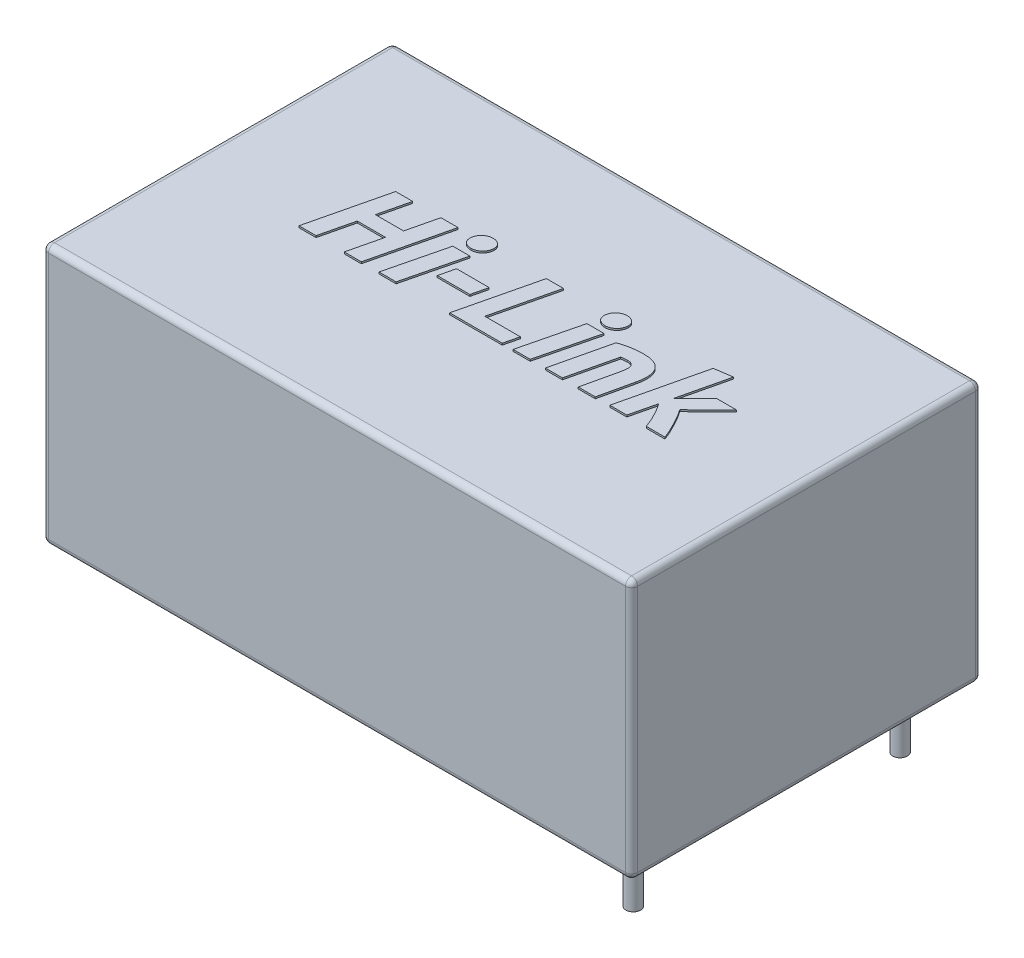
from build123d import *

# Parameters (mm, degrees)
SKETCH1_W           = 34
SKETCH1_H           = 20.2
BOSS_EXTRUDE2_DEPTH = 15
SKETCH2_R           = 0.423333333
BOSS_EXTRUDE3_DEPTH = 3.5
BOSS_EXTRUDE4_DEPTH = 0.1
FILLET1_R           = 0.35


with BuildPart() as part:
    # Sketch1 → Boss-Extrude2 (new body)
    with BuildSketch(Plane(origin=(0, 0, 0), x_dir=(1, 0, 0), z_dir=(0, 1, 0))):
        with Locations((17, 10.1)):
            Rectangle(SKETCH1_W, SKETCH1_H)
    extrude(amount=BOSS_EXTRUDE2_DEPTH)

    # Sketch2 → Boss-Extrude3 (add)
    with BuildSketch(Plane.XZ):
        with Locations((2.3, -7.6)):
            Circle(SKETCH2_R)
        with Locations((2.3, -12.6)):
            Circle(SKETCH2_R)
        with Locations((31.7, -17.8)):
            Circle(SKETCH2_R)
        with Locations((31.7, -2.4)):
            Circle(SKETCH2_R)
    extrude(amount=BOSS_EXTRUDE3_DEPTH)

    # Sketch3 → Boss-Extrude4 (add)
    with BuildSketch(Plane(origin=(0, 15, 0), x_dir=(1, 0, 0), z_dir=(0, 1, 0))):
        Polygon((10.350318867, 12.648491232), (11.335631367, 12.648491232), (10.255631367, 8.148491232), (9.270318867, 8.148491232), (9.730631367, 10.068491232), (8.102193867, 10.068491232), (7.640943867, 8.148491232), (6.655631367, 8.148491232), (7.735631367, 12.648491232), (8.720943867, 12.648491232), (8.303756367, 10.908491232), (9.932193867, 10.908491232), align=None)
        Polygon((12.261881367, 8.148491232), (11.275631367, 8.148491232), (12.115631367, 11.568491232), (13.101881367, 11.568491232), align=None)
        with BuildLine():
            add(Edge.make_bspline(
                [(12.740006367, 11.988491232), (12.706750428, 11.989888935), (12.641017262, 11.992651612), (12.54504248, 12.016096214), (12.454021343, 12.054198845), (12.3693054, 12.105674787), (12.294416137, 12.172543008), (12.243861168, 12.260416221), (12.211281809, 12.362167754), (12.208198927, 12.435396738), (12.206568867, 12.474116232)],
                knots=[0, 0, 0, 0, 9.9658e-05, 0.000196982, 0.000294482, 0.000394654, 0.000493483, 0.000591881, 0.000695065, 0.000810838, 0.000810838, 0.000810838, 0.000810838], degree=3))
            add(Edge.make_bspline(
                [(12.206568867, 12.474116232), (12.207357098, 12.496343093), (12.208930749, 12.540717558), (12.219492999, 12.606075401), (12.236249223, 12.669738795), (12.268866548, 12.750285776), (12.323943973, 12.842894269), (12.407325184, 12.940573536), (12.508626271, 13.019793742), (12.60483926, 13.068914927), (12.686220664, 13.101077481), (12.751075332, 13.115914271), (12.817405536, 13.127527259), (12.862451292, 13.128166646), (12.885318867, 13.128491232)],
                knots=[0, 0, 0, 0, 6.6668e-05, 0.000133098, 0.000198138, 0.00026377, 0.000393203, 0.000519497, 0.000647028, 0.000776186, 0.000842351, 0.000908973, 0.000975403, 0.001043899, 0.001043899, 0.001043899, 0.001043899], degree=3))
            add(Edge.make_bspline(
                [(12.885318867, 13.128491232), (12.918576393, 13.127096805), (12.984312696, 13.124340602), (13.080264362, 13.100848286), (13.171127637, 13.063030516), (13.25530803, 13.011054492), (13.329504145, 12.944303), (13.382141217, 12.857414255), (13.413780196, 12.755003721), (13.417039853, 12.681547702), (13.418756367, 12.642866232)],
                knots=[0, 0, 0, 0, 9.9658e-05, 0.000196982, 0.000294482, 0.000393857, 0.000492686, 0.00059077, 0.00069485, 0.000810623, 0.000810623, 0.000810623, 0.000810623], degree=3))
            add(Edge.make_bspline(
                [(13.418756367, 12.642866232), (13.417941865, 12.620646406), (13.416315764, 12.576285984), (13.40613027, 12.510741396), (13.387881816, 12.447390668), (13.355613399, 12.36688625), (13.301602123, 12.273466563), (13.217070196, 12.176966807), (13.116315683, 12.097232276), (13.001738312, 12.036211452), (12.874488614, 11.995753427), (12.785308356, 11.990937591), (12.740006367, 11.988491232)],
                knots=[0, 0, 0, 0, 6.6668e-05, 0.000133098, 0.000198388, 0.000264019, 0.000392979, 0.000519889, 0.000646683, 0.000776279, 0.000907653, 0.001043289, 0.001043289, 0.001043289, 0.001043289], degree=3))
        make_face()
        Polygon((13.350318867, 10.548491232), (15.235631367, 10.548491232), (15.020943867, 9.648491232), (13.135631367, 9.648491232), align=None)
        Polygon((18.595631367, 8.988491232), (18.388443867, 8.148491232), (15.355631367, 8.148491232), (16.435631367, 12.648491232), (17.420943867, 12.648491232), (16.542506367, 8.988491232), align=None)
        Polygon((20.001881367, 8.148491232), (19.015631367, 8.148491232), (19.855631367, 11.568491232), (20.841881367, 11.568491232), align=None)
        with BuildLine():
            add(Edge.make_bspline(
                [(20.480006367, 11.988491232), (20.446750428, 11.989888935), (20.381017262, 11.992651612), (20.28504248, 12.016096214), (20.194021343, 12.054198845), (20.1093054, 12.105674787), (20.034416137, 12.172543008), (19.983861168, 12.260416221), (19.951281809, 12.362167754), (19.948198927, 12.435396738), (19.946568867, 12.474116232)],
                knots=[0, 0, 0, 0, 9.9658e-05, 0.000196982, 0.000294482, 0.000394654, 0.000493483, 0.000591881, 0.000695065, 0.000810838, 0.000810838, 0.000810838, 0.000810838], degree=3))
            add(Edge.make_bspline(
                [(19.946568867, 12.474116232), (19.947357098, 12.496343093), (19.948930749, 12.540717558), (19.959492999, 12.606075401), (19.976249223, 12.669738795), (20.008866548, 12.750285776), (20.063943973, 12.842894269), (20.147325184, 12.940573536), (20.248626271, 13.019793742), (20.34483926, 13.068914927), (20.426220664, 13.101077481), (20.491075332, 13.115914271), (20.557405536, 13.127527259), (20.602451292, 13.128166646), (20.625318867, 13.128491232)],
                knots=[0, 0, 0, 0, 6.6668e-05, 0.000133098, 0.000198138, 0.00026377, 0.000393203, 0.000519497, 0.000647028, 0.000776186, 0.000842351, 0.000908973, 0.000975403, 0.001043899, 0.001043899, 0.001043899, 0.001043899], degree=3))
            add(Edge.make_bspline(
                [(20.625318867, 13.128491232), (20.658576393, 13.127096805), (20.724312696, 13.124340602), (20.820264362, 13.100848286), (20.911127637, 13.063030516), (20.99530803, 13.011054492), (21.069504145, 12.944303), (21.122141217, 12.857414255), (21.153780196, 12.755003721), (21.157039853, 12.681547702), (21.158756367, 12.642866232)],
                knots=[0, 0, 0, 0, 9.9658e-05, 0.000196982, 0.000294482, 0.000393857, 0.000492686, 0.00059077, 0.00069485, 0.000810623, 0.000810623, 0.000810623, 0.000810623], degree=3))
            add(Edge.make_bspline(
                [(21.158756367, 12.642866232), (21.157941865, 12.620646406), (21.156315764, 12.576285984), (21.14613027, 12.510741396), (21.127881816, 12.447390668), (21.095613399, 12.36688625), (21.041602123, 12.273466563), (20.957070196, 12.176966807), (20.856315683, 12.097232276), (20.741738312, 12.036211452), (20.614488614, 11.995753427), (20.525308356, 11.990937591), (20.480006367, 11.988491232)],
                knots=[0, 0, 0, 0, 6.6668e-05, 0.000133098, 0.000198388, 0.000264019, 0.000392979, 0.000519889, 0.000646683, 0.000776279, 0.000907653, 0.001043289, 0.001043289, 0.001043289, 0.001043289], degree=3))
        make_face()
        with BuildLine():
            add(Edge.make_bspline(
                [(21.655631367, 11.455053732), (21.694398758, 11.466872739), (21.775713577, 11.491663173), (21.903597615, 11.531927081), (22.04509038, 11.572676382), (22.202877161, 11.610394733), (22.37853131, 11.643649774), (22.537885511, 11.663095364), (22.675757887, 11.677453166), (22.788407999, 11.68302726), (22.907765569, 11.688576227), (22.98968583, 11.688520128), (23.031881367, 11.688491232)],
                knots=[0, 0, 0, 0, 0.000121586, 0.000255028, 0.000402218, 0.000563209, 0.000741566, 0.000938202, 0.00104464, 0.001157331, 0.001276486, 0.001403052, 0.001403052, 0.001403052, 0.001403052], degree=3))
            add(Edge.make_bspline(
                [(23.031881367, 11.688491232), (23.093181979, 11.687309884), (23.211124792, 11.685036963), (23.38103945, 11.665572238), (23.53576359, 11.631944478), (23.676366036, 11.586702488), (23.801176552, 11.526266638), (23.911758767, 11.452880216), (24.006060591, 11.364644459), (24.086245227, 11.264136634), (24.14939682, 11.150530075), (24.200073651, 11.026381199), (24.23393177, 10.890280162), (24.254591162, 10.743253719), (24.259618917, 10.584943235), (24.249589007, 10.415342238), (24.225113184, 10.23456647), (24.198667148, 10.11145819), (24.185006367, 10.047866232)],
                knots=[0, 0, 0, 0, 0.000183867, 0.000353762, 0.000512088, 0.000658245, 0.000795773, 0.000926822, 0.001054849, 0.001181644, 0.001310951, 0.001443434, 0.001582819, 0.001730516, 0.001888116, 0.002057127, 0.002239699, 0.002434773, 0.002434773, 0.002434773, 0.002434773], degree=3))
            Line((24.185006367, 10.047866232), (23.755631367, 8.148491232))
            Line((23.755631367, 8.148491232), (22.773131367, 8.148491232))
            Line((22.773131367, 8.148491232), (23.201568867, 10.026303732))
            add(Edge.make_bspline(
                [(23.201568867, 10.026303732), (23.213972637, 10.083390101), (23.238006866, 10.194003803), (23.260203226, 10.331211881), (23.273048386, 10.435438585), (23.274599661, 10.507905504), (23.271323468, 10.575728759), (23.261199843, 10.638390262), (23.244505469, 10.696280452), (23.220366629, 10.74880796), (23.18625531, 10.794612409), (23.145000682, 10.835587286), (23.092851234, 10.869586477), (23.028416418, 10.892402016), (22.952477588, 10.906300512), (22.897887499, 10.907728962), (22.868756367, 10.908491232)],
                knots=[0, 0, 0, 0, 0.000175222, 0.00033952, 0.000416857, 0.000490006, 0.000556674, 0.000620327, 0.000679953, 0.000736986, 0.000792679, 0.000850356, 0.000910685, 0.000977728, 0.001054034, 0.001141348, 0.001141348, 0.001141348, 0.001141348], degree=3))
            add(Edge.make_bspline(
                [(22.868756367, 10.908491232), (22.807957529, 10.906995952), (22.684693388, 10.903964406), (22.563572869, 10.880836515), (22.502193867, 10.869116232)],
                knots=[0, 0, 0, 0, 0.000182116, 0.000369225, 0.000369225, 0.000369225, 0.000369225], degree=3))
            Line((22.502193867, 10.869116232), (21.860006367, 8.148491232))
            Line((21.860006367, 8.148491232), (20.875631367, 8.148491232))
            Line((20.875631367, 8.148491232), (21.655631367, 11.455053732))
        make_face()
        with BuildLine():
            add(Edge.make_bspline(
                [(26.093756367, 10.325366232), (26.204923143, 10.434513685), (26.428046701, 10.653584246), (26.707138177, 10.925097922), (26.924550618, 11.139893889), (27.079990918, 11.290370103), (27.22367816, 11.433263792), (27.317128289, 11.52449548), (27.362193867, 11.568491232)],
                knots=[0, 0, 0, 0, 0.000467376, 0.000938074, 0.001168114, 0.001384239, 0.001587095, 0.001776035, 0.001776035, 0.001776035, 0.001776035], degree=3))
            Line((27.362193867, 11.568491232), (28.495631367, 11.568491232))
            add(Edge.make_bspline(
                [(28.495631367, 11.568491232), (28.36094889, 11.436298615), (28.094107037, 11.174389837), (27.760323056, 10.846924454), (27.491495627, 10.583253379), (27.282439522, 10.37761564), (27.063665986, 10.163896009), (26.914986679, 10.018198828), (26.839068867, 9.943803732)],
                knots=[0, 0, 0, 0, 0.000566152, 0.001121698, 0.001402786, 0.001695805, 0.002001426, 0.002320304, 0.002320304, 0.002320304, 0.002320304], degree=3))
            add(Edge.make_bspline(
                [(26.839068867, 9.943803732), (26.882071676, 9.884347494), (26.972462056, 9.759372589), (27.096484102, 9.553381487), (27.224382473, 9.331824671), (27.348173746, 9.097300642), (27.471453211, 8.857777977), (27.585524831, 8.616291233), (27.69079402, 8.381213078), (27.748051249, 8.224147725), (27.775631367, 8.148491232)],
                knots=[0, 0, 0, 0, 0.000220041, 0.000462519, 0.000720782, 0.000987529, 0.001257961, 0.00152886, 0.00178873, 0.002030238, 0.002030238, 0.002030238, 0.002030238], degree=3))
            Line((27.775631367, 8.148491232), (26.703131367, 8.148491232))
            add(Edge.make_bspline(
                [(26.703131367, 8.148491232), (26.681790121, 8.208384667), (26.636835836, 8.334547239), (26.556009684, 8.526168504), (26.467313526, 8.726551803), (26.366958664, 8.925481804), (26.262077993, 9.119123076), (26.15371301, 9.30305229), (26.045199667, 9.474036357), (25.96717046, 9.579221793), (25.929693867, 9.629741232)],
                knots=[0, 0, 0, 0, 0.000190709, 0.00040172, 0.000623701, 0.000848007, 0.001069925, 0.001284252, 0.001488388, 0.00167704, 0.00167704, 0.00167704, 0.00167704], degree=3))
            Line((25.929693867, 9.629741232), (25.579068867, 8.148491232))
            Line((25.579068867, 8.148491232), (24.595631367, 8.148491232))
            Line((24.595631367, 8.148491232), (25.735631367, 12.972866232))
            Line((25.735631367, 12.972866232), (26.756568867, 13.128491232))
            Line((26.756568867, 13.128491232), (26.093756367, 10.325366232))
        make_face()
    extrude(amount=BOSS_EXTRUDE4_DEPTH)

    # Fillet1
    fillet1_edges = [part.edges().sort_by_distance(p)[0] for p in [
        (34, 15, -10.1),
        (17, 15, -20.2),
        (0, 15, -10.1),
        (17, 0, -20.2),
        (34, 0, -10.1),
        (17, 0, 0),
        (0, 0, -10.1),
        (17, 15, 0),
        (0, 7.5, -20.2),
        (34, 7.5, -20.2),
        (34, 7.5, 0),
        (0, 7.5, 0),
    ]]
    fillet(fillet1_edges, radius=FILLET1_R)


solid = part.part
